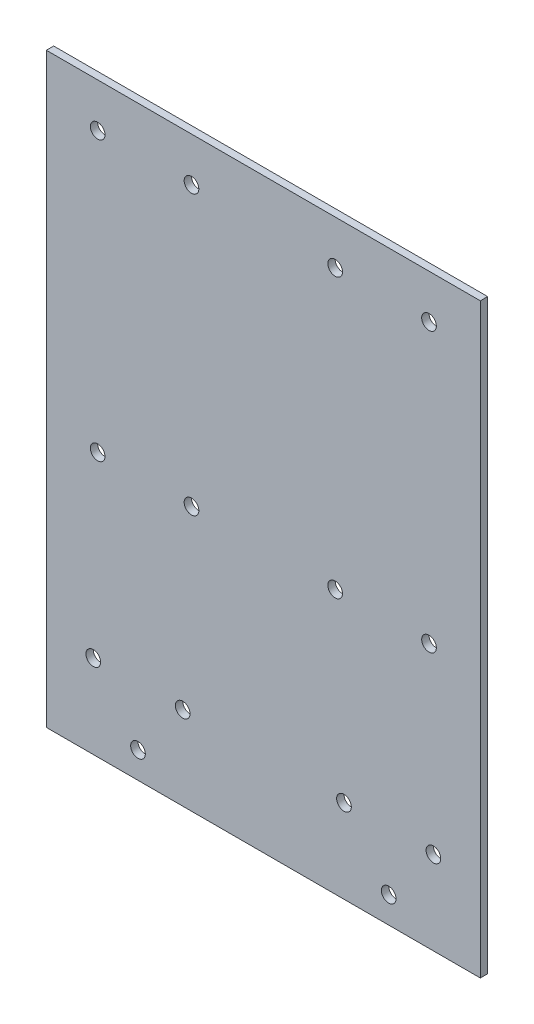
from build123d import *

# Parameters (mm, degrees)
SKETCH_1_W          = 148
SKETCH_1_H          = 200
SKETCH_1_R          = 2.5
EXTRUDE_1_DEPTH     = 2.5
SKETCH_2_R          = 2.5
CUT_EXTRUDE_1_DEPTH = 3


with BuildPart() as part:
    # 草图1 → 凸台-拉伸1 (new body)
    with BuildSketch(Plane.XY):
        Rectangle(SKETCH_1_W, SKETCH_1_H)
        with Locations((-58, -71.5)):
            Circle(SKETCH_1_R, mode=Mode.SUBTRACT)
        with Locations((-27.5, -71.5)):
            Circle(SKETCH_1_R, mode=Mode.SUBTRACT)
        with Locations((-42.75, -91)):
            Circle(SKETCH_1_R, mode=Mode.SUBTRACT)
        with Locations((42.75, -91)):
            Circle(SKETCH_1_R, mode=Mode.SUBTRACT)
        with Locations((58, -71.5)):
            Circle(SKETCH_1_R, mode=Mode.SUBTRACT)
        with Locations((27.5, -71.5)):
            Circle(SKETCH_1_R, mode=Mode.SUBTRACT)
    extrude(amount=EXTRUDE_1_DEPTH)

    # 草图2 → 切除-拉伸1 (cut)
    with BuildSketch(Plane.XY.offset(2.5)):
        with Locations((-56.5, -10)):
            Circle(SKETCH_2_R)
        with Locations((-24.5, -10)):
            Circle(SKETCH_2_R)
        with Locations((-56.5, 85)):
            Circle(SKETCH_2_R)
        with Locations((-24.5, 85)):
            Circle(SKETCH_2_R)
        with Locations((24.5, 85)):
            Circle(SKETCH_2_R)
        with Locations((56.5, 85)):
            Circle(SKETCH_2_R)
        with Locations((24.5, -10)):
            Circle(SKETCH_2_R)
        with Locations((56.5, -10)):
            Circle(SKETCH_2_R)
    extrude(amount=-CUT_EXTRUDE_1_DEPTH, mode=Mode.SUBTRACT)


solid = part.part
